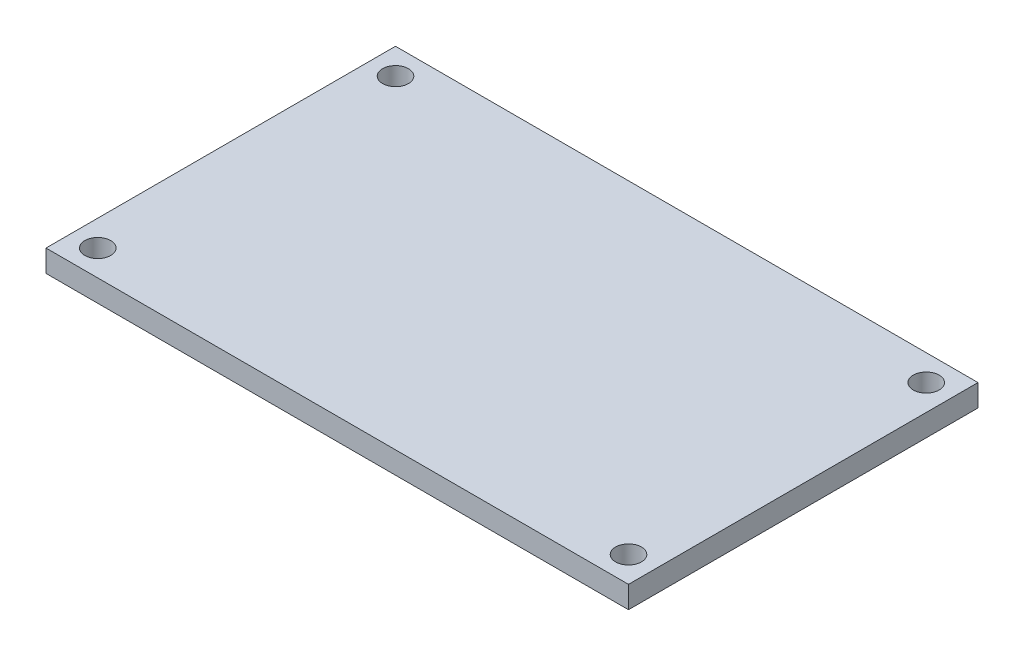
from build123d import *

# Parameters (mm, degrees)
ESBO_O1_W                = 45
ESBO_O1_H                = 27
RESSALTO_EXTRUS_O1_DEPTH = 1.7
RESSALTO_EXTRUS_O2_DEPTH = 1
ESBO_O3_R                = 1
CORTE_EXTRUS_O1_DEPTH    = 2.7


with BuildPart() as part:
    # Esboço1 → Ressalto-extrusão1 (new body)
    with BuildSketch(Plane(origin=(0, 0, 0), x_dir=(1, 0, 0), z_dir=(0, 1, 0))):
        with Locations((22.5, 13.5)):
            Rectangle(ESBO_O1_W, ESBO_O1_H)
    extrude(amount=RESSALTO_EXTRUS_O1_DEPTH)

    # Esboço2 → Ressalto-extrusão2 (add)
    with BuildSketch(Plane.XZ):
        Polygon((3, -22.5), (5, -24.5), (40, -24.5), (42, -22.5), (42, -4.5), (40, -2.5), (5, -2.5), (3, -4.5), align=None)
    extrude(amount=RESSALTO_EXTRUS_O2_DEPTH)

    # Esboço3 → Corte-extrusão1 (cut, through all)
    with BuildSketch(Plane.XZ):
        with Locations((2, -25)):
            Circle(ESBO_O3_R)
        with Locations((43, -25)):
            Circle(ESBO_O3_R)
        with Locations((43, -2)):
            Circle(ESBO_O3_R)
        with Locations((2, -2)):
            Circle(ESBO_O3_R)
    extrude(amount=-CORTE_EXTRUS_O1_DEPTH, mode=Mode.SUBTRACT)


solid = part.part
